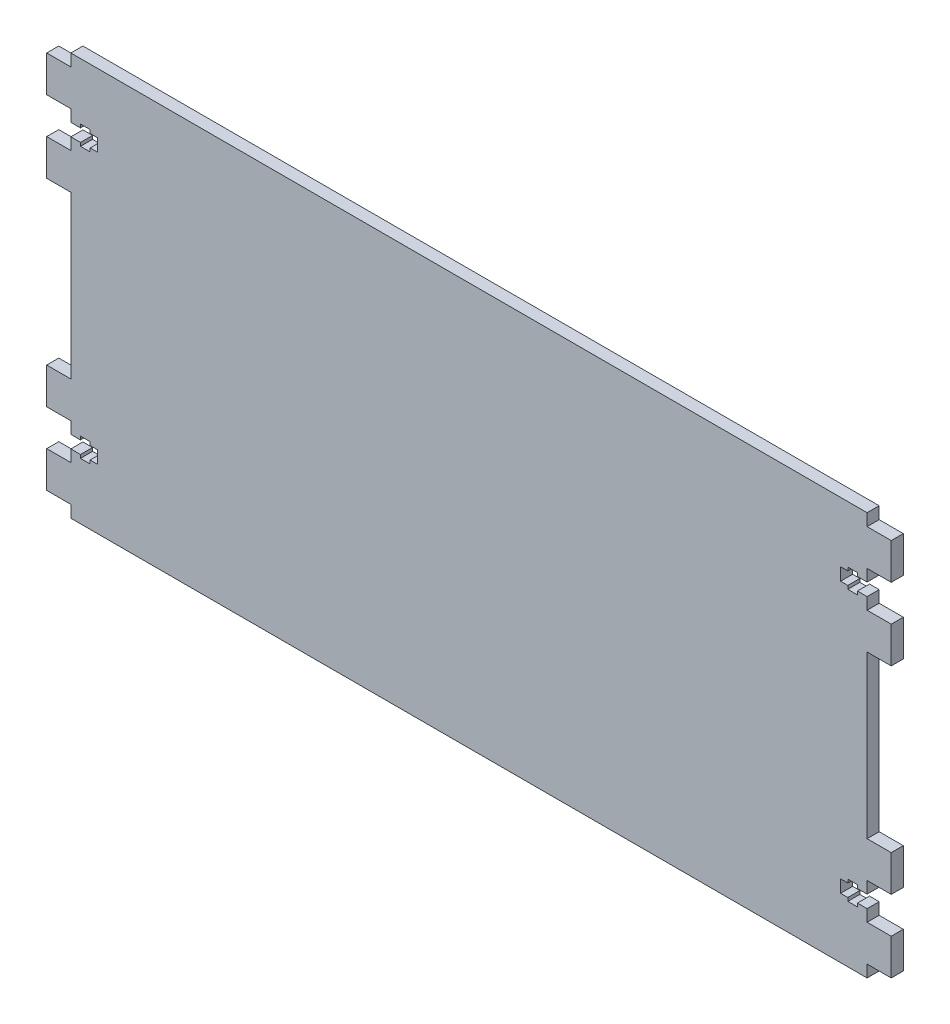
from build123d import *

# Parameters (mm, degrees)
SKETCH1_W               = 330
SKETCH1_H               = 167
BOSS_EXTRUDE1_DEPTH     = 2.5
SKETCH2_W               = 5
SKETCH2_H               = 15
BOSS_EXTRUDE2_DEPTH     = 10
SKETCH4_W               = 11
SKETCH4_H               = 5.2
CUT_EXTRUDE1_DEPTH      = 6
SKETCH5_W               = 4
SKETCH5_H               = 8
CUT_EXTRUDE2_DEPTH      = 6
MIRROR2_COPY_1_SKETCH_W = 5
MIRROR2_COPY_1_SKETCH_H = 15
MIRROR2_COPY_1_DEPTH    = 10
MIRROR2_COPY_2_SKETCH_W = 11
MIRROR2_COPY_2_SKETCH_H = 5.2
MIRROR2_COPY_2_DEPTH    = 6
MIRROR2_COPY_3_SKETCH_W = 4
MIRROR2_COPY_3_SKETCH_H = 8
MIRROR2_COPY_3_DEPTH    = 6


with BuildPart() as part:
    # Sketch1 → Boss-Extrude1 (new body, symmetric)
    with BuildSketch(Plane.XY):
        Rectangle(SKETCH1_W, SKETCH1_H)
    extrude(amount=BOSS_EXTRUDE1_DEPTH, both=True)

    # Sketch2 → Boss-Extrude2 (add)
    with BuildSketch(Plane.ZY.offset(165)):
        with Locations((0, 71)):
            Rectangle(SKETCH2_W, SKETCH2_H)
        with Locations((0, 41)):
            Rectangle(SKETCH2_W, SKETCH2_H)
    boss_extrude2 = extrude(amount=BOSS_EXTRUDE2_DEPTH)

    # Sketch4 → Cut-Extrude1 (cut, through all)
    with BuildSketch(Plane.XY.offset(2.5)):
        with Locations((-159.5, 56)):
            Rectangle(SKETCH4_W, SKETCH4_H)
    cut_extrude1 = extrude(amount=-CUT_EXTRUDE1_DEPTH, mode=Mode.SUBTRACT)

    # Sketch5 → Cut-Extrude2 (cut, through all)
    with BuildSketch(Plane.XY.offset(2.5)):
        with Locations((-159, 56)):
            Rectangle(SKETCH5_W, SKETCH5_H)
    cut_extrude2 = extrude(amount=-CUT_EXTRUDE2_DEPTH, mode=Mode.SUBTRACT)

    # Mirror1: Boss-Extrude2, Cut-Extrude1, Cut-Extrude2 across plane
    add(boss_extrude2.mirror(Plane.ZX))
    add(cut_extrude1.mirror(Plane.ZX), mode=Mode.SUBTRACT)
    add(cut_extrude2.mirror(Plane.ZX), mode=Mode.SUBTRACT)

    # Mirror2: Boss-Extrude2, Cut-Extrude1, Cut-Extrude2 across plane
    add(boss_extrude2.mirror(Plane(origin=(0, 0, 0), x_dir=(0, 0, 1), z_dir=(1, 0, 0))))
    add(cut_extrude1.mirror(Plane(origin=(0, 0, 0), x_dir=(0, 0, 1), z_dir=(1, 0, 0))), mode=Mode.SUBTRACT)
    add(cut_extrude2.mirror(Plane(origin=(0, 0, 0), x_dir=(0, 0, 1), z_dir=(1, 0, 0))), mode=Mode.SUBTRACT)

    # Mirror2 copy 1 sketch → Mirror2 copy 1 (add)
    with BuildSketch(Plane(origin=(165, 0, 0), x_dir=(0, 0, 1), z_dir=(1, 0, 0))):
        with Locations((0, 71)):
            Rectangle(MIRROR2_COPY_1_SKETCH_W, MIRROR2_COPY_1_SKETCH_H)
        with Locations((0, 41)):
            Rectangle(MIRROR2_COPY_1_SKETCH_W, MIRROR2_COPY_1_SKETCH_H)
    extrude(amount=MIRROR2_COPY_1_DEPTH)

    # Mirror2 copy 2 sketch → Mirror2 copy 2 (cut, through all)
    with BuildSketch(Plane(origin=(0, 0, 2.5), x_dir=(-1, 0, 0), z_dir=(0, 0, 1))):
        with Locations((-159.5, 56)):
            Rectangle(MIRROR2_COPY_2_SKETCH_W, MIRROR2_COPY_2_SKETCH_H)
    extrude(amount=-MIRROR2_COPY_2_DEPTH, mode=Mode.SUBTRACT)

    # Mirror2 copy 3 sketch → Mirror2 copy 3 (cut, through all)
    with BuildSketch(Plane(origin=(0, 0, 2.5), x_dir=(-1, 0, 0), z_dir=(0, 0, 1))):
        with Locations((-159, 56)):
            Rectangle(MIRROR2_COPY_3_SKETCH_W, MIRROR2_COPY_3_SKETCH_H)
    extrude(amount=-MIRROR2_COPY_3_DEPTH, mode=Mode.SUBTRACT)


solid = part.part
